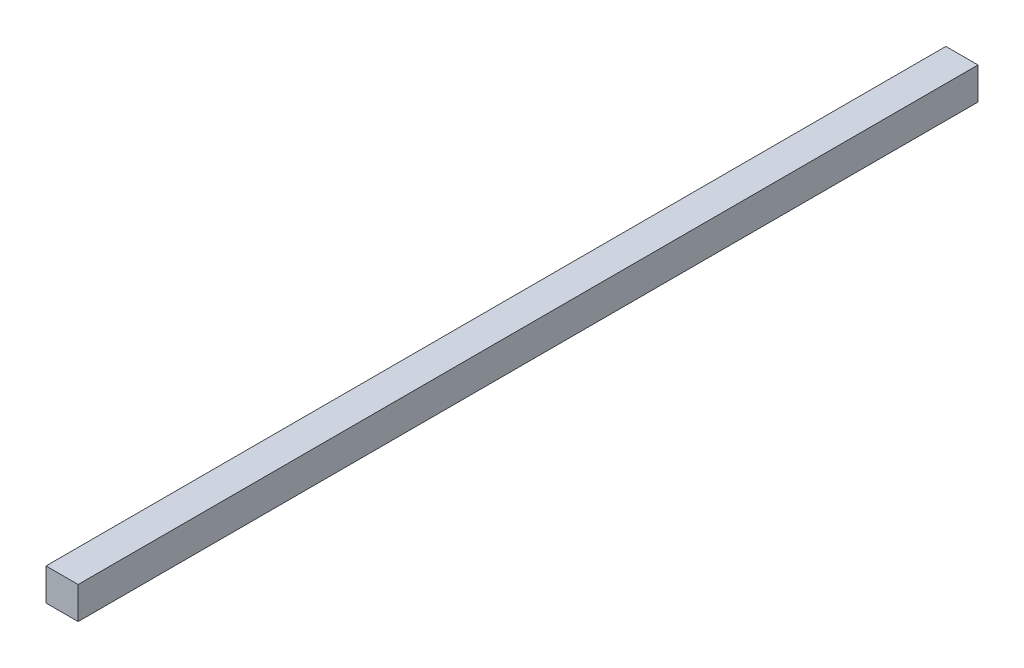
from build123d import *

# Parameters (mm, degrees)
ESQUISSE1_W        = 15
ESQUISSE1_H        = 15
BOSS_EXTRU_1_DEPTH = 420


with BuildPart() as part:
    # Esquisse1 → Boss.-Extru.1 (new body)
    with BuildSketch(Plane.XY):
        Rectangle(ESQUISSE1_W, ESQUISSE1_H)
    extrude(amount=BOSS_EXTRU_1_DEPTH)


solid = part.part
